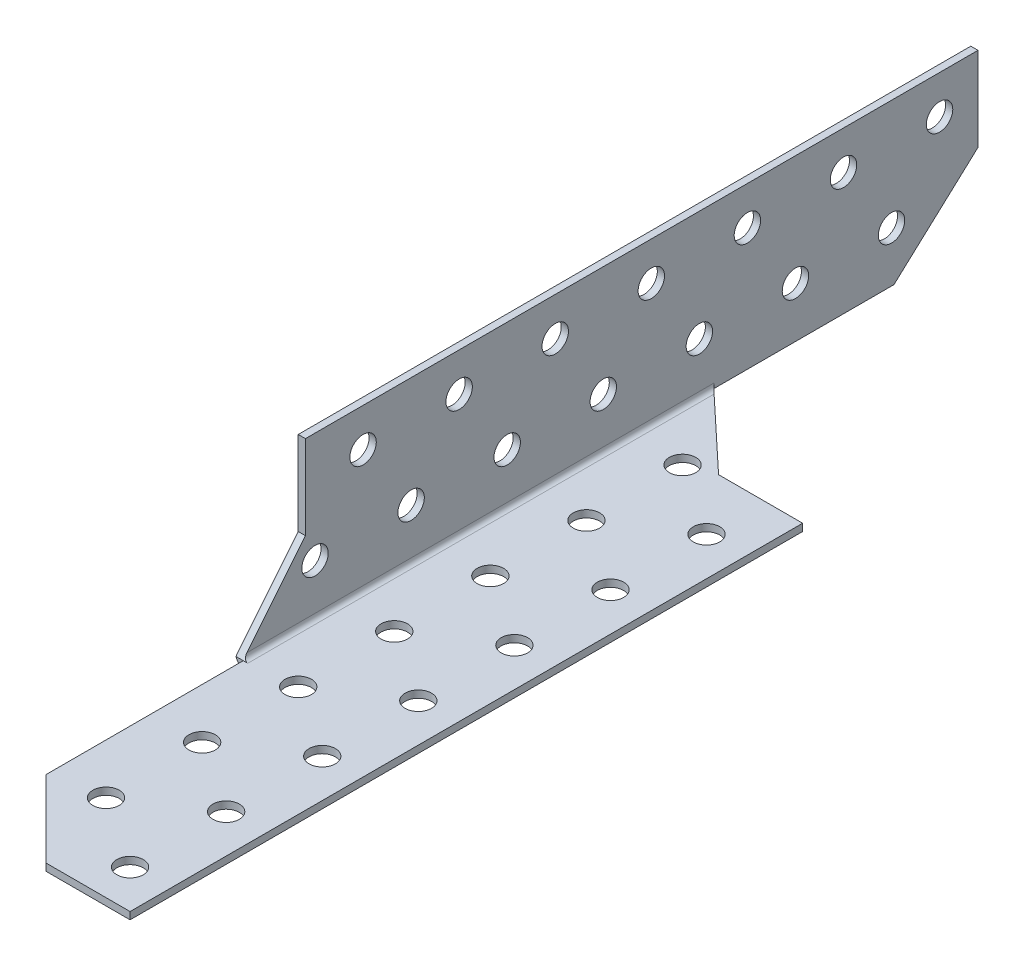
from build123d import *

# Parameters (mm, degrees)
SKETCH1_W               = 1.5
SKETCH1_H               = 33.5
SKETCH1_W_2             = 33.5
SKETCH1_H_2             = 1.5
BOSS_EXTRUDE1_DEPTH     = 210
CUT_EXTRUDE2_DEPTH      = 62
CUT_EXTRUDE2_DEPTH_BACK = 62
CUT_EXTRUDE3_DEPTH      = 62
SKETCH5_R               = 2.75
CUT_EXTRUDE4_DEPTH      = 5
FILLET1_R               = 1
FILLET2_R               = 2
SKETCH6_W               = 37.5
SKETCH6_H               = 1.436491673
CUT_EXTRUDE5_DEPTH      = 5
SKETCH7_W               = 1.5
SKETCH7_H               = 45.359757049
CUT_EXTRUDE6_DEPTH      = 5
SKETCH8_R               = 2.75
CUT_EXTRUDE7_DEPTH      = 5


with BuildPart() as part:
    # Sketch1 → Boss-Extrude1 (new body)
    with BuildSketch(Plane.XY):
        with Locations((0, 0.75)):
            Rectangle(SKETCH1_W, SKETCH1_H)
        with Locations((17.5, -16.75)):
            Rectangle(SKETCH1_W_2, SKETCH1_H_2)
        with Locations((0, -16.75)):
            Rectangle(SKETCH1_W, SKETCH1_H_2)
    extrude(amount=BOSS_EXTRUDE1_DEPTH)

    # Sketch3 → Cut-Extrude2 (cut, two sides)
    with BuildSketch(Plane(origin=(0.75, 0, 0), x_dir=(0, 0, -1), z_dir=(1, 0, 0))) as cut_extrude2_sk:
        Polygon((-140, 17.5), (-140, 0), (-153, -16), (-210, -16), (-210, 17.5), align=None)
        Polygon((0, 0), (-17.5, -16), (-17.5, -36.829348397), (0, -36.829348397), align=None)
    extrude(amount=CUT_EXTRUDE2_DEPTH, mode=Mode.SUBTRACT)
    extrude(cut_extrude2_sk.sketch, amount=-CUT_EXTRUDE2_DEPTH_BACK, mode=Mode.SUBTRACT)

    # Sketch4 → Cut-Extrude3 (cut)
    with BuildSketch(Plane(origin=(0, -16, 0), x_dir=(1, 0, 0), z_dir=(0, 1, 0))):
        Polygon((16.75, -210), (-0.75, -192.5), (-0.75, -210), align=None)
        Polygon((34.25, -70), (16.75, -70), (0.75, -55), (0.75, -17.5), (34.25, -17.5), align=None)
    extrude(amount=-CUT_EXTRUDE3_DEPTH, mode=Mode.SUBTRACT)

    # Sketch5 → Cut-Extrude4 (cut)
    with BuildSketch(Plane(origin=(0.75, 0, 0), x_dir=(0, 0, -1), z_dir=(1, 0, 0))):
        with Locations(Location((-8, 9.5, 0), (0, 0, 90))):
            Circle(SKETCH5_R)
        with Locations(Location((-28, 9.5, 0), (0, 0, 90))):
            Circle(SKETCH5_R)
        with Locations(Location((-48, 9.5, 0), (0, 0, 90))):
            Circle(SKETCH5_R)
        with Locations(Location((-68, 9.5, 0), (0, 0, 90))):
            Circle(SKETCH5_R)
        with Locations(Location((-88, 9.5, 0), (0, 0, 90))):
            Circle(SKETCH5_R)
        with Locations(Location((-108, 9.5, 0), (0, 0, 90))):
            Circle(SKETCH5_R)
        with Locations(Location((-128, 9.5, 0), (0, 0, 90))):
            Circle(SKETCH5_R)
        with Locations(Location((-18, -5.5, 0), (0, 0, 90))):
            Circle(SKETCH5_R)
        with Locations(Location((-38, -5.5, 0), (0, 0, 90))):
            Circle(SKETCH5_R)
        with Locations(Location((-58, -5.5, 0), (0, 0, 90))):
            Circle(SKETCH5_R)
        with Locations(Location((-78, -5.5, 0), (0, 0, 90))):
            Circle(SKETCH5_R)
        with Locations(Location((-98, -5.5, 0), (0, 0, 90))):
            Circle(SKETCH5_R)
        with Locations(Location((-118, -5.5, 0), (0, 0, 90))):
            Circle(SKETCH5_R)
        with Locations(Location((-138, -5.5, 0), (0, 0, 90))):
            Circle(SKETCH5_R)
    extrude(amount=-CUT_EXTRUDE4_DEPTH, mode=Mode.SUBTRACT)

    # Fillet1
    fillet1_edges = [part.edges().sort_by_distance(p)[0] for p in [
        (0.75, -16, 104),
    ]]
    fillet(fillet1_edges, radius=FILLET1_R)

    # Fillet2
    fillet2_edges = [part.edges().sort_by_distance(p)[0] for p in [
        (-0.75, -17.5, 105),
    ]]
    fillet(fillet2_edges, radius=FILLET2_R)

    # Sketch6 → Cut-Extrude5 (cut)
    with BuildSketch(Plane(origin=(0.75, 0, 0), x_dir=(0, 0, -1), z_dir=(1, 0, 0))):
        with Locations((-36.25, -16.718245837)):
            Rectangle(SKETCH6_W, SKETCH6_H)
    extrude(amount=-CUT_EXTRUDE5_DEPTH, mode=Mode.SUBTRACT)

    # Sketch7 → Cut-Extrude6 (cut)
    with BuildSketch(Plane(origin=(0, -16, 0), x_dir=(1, 0, 0), z_dir=(0, 1, 0))):
        with Locations((0.063508327, -175.679878524)):
            Rectangle(SKETCH7_W, SKETCH7_H)
    extrude(amount=-CUT_EXTRUDE6_DEPTH, mode=Mode.SUBTRACT)

    # Sketch8 → Cut-Extrude7 (cut)
    with BuildSketch(Plane(origin=(0, -16, 0), x_dir=(1, 0, 0), z_dir=(0, 1, 0))):
        with Locations(Location((11.25, -72, 0), (0, 0, 270))):
            Circle(SKETCH8_R)
        with Locations(Location((11.25, -92, 0), (0, 0, 270))):
            Circle(SKETCH8_R)
        with Locations(Location((11.25, -112, 0), (0, 0, 270))):
            Circle(SKETCH8_R)
        with Locations(Location((11.25, -132, 0), (0, 0, 270))):
            Circle(SKETCH8_R)
        with Locations(Location((11.25, -152, 0), (0, 0, 270))):
            Circle(SKETCH8_R)
        with Locations(Location((11.25, -172, 0), (0, 0, 270))):
            Circle(SKETCH8_R)
        with Locations(Location((11.25, -192, 0), (0, 0, 270))):
            Circle(SKETCH8_R)
        with Locations(Location((26.25, -82, 0), (0, 0, 270))):
            Circle(SKETCH8_R)
        with Locations(Location((26.25, -102, 0), (0, 0, 270))):
            Circle(SKETCH8_R)
        with Locations(Location((26.25, -122, 0), (0, 0, 270))):
            Circle(SKETCH8_R)
        with Locations(Location((26.25, -142, 0), (0, 0, 270))):
            Circle(SKETCH8_R)
        with Locations(Location((26.25, -162, 0), (0, 0, 270))):
            Circle(SKETCH8_R)
        with Locations(Location((26.25, -182, 0), (0, 0, 270))):
            Circle(SKETCH8_R)
        with Locations(Location((26.25, -202, 0), (0, 0, 270))):
            Circle(SKETCH8_R)
    extrude(amount=-CUT_EXTRUDE7_DEPTH, mode=Mode.SUBTRACT)


solid = part.part
